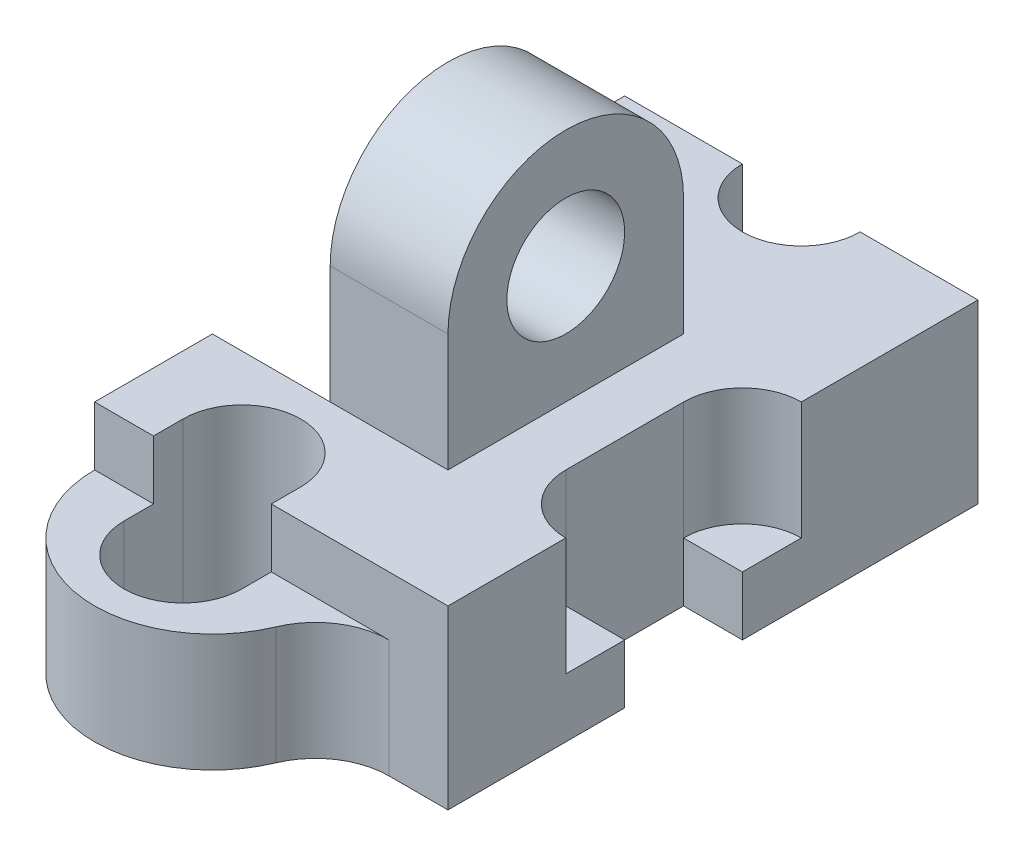
from build123d import *

# Parameters (mm, degrees)
SKETCH1_W           = 6
SKETCH1_H           = 3
BOSS_EXTRUDE1_DEPTH = 9
BOSS_EXTRUDE2_DEPTH = 2
CUT_EXTRUDE1_DEPTH  = 2.5
SKETCH4_W           = 1
SKETCH4_H           = 2
CUT_EXTRUDE2_DEPTH  = 1
CUT_EXTRUDE3_DEPTH  = 2
CUT_EXTRUDE4_DEPTH  = 1
CUT_EXTRUDE5_DEPTH  = 4
SKETCH8_W           = 2
SKETCH8_H           = 4
BOSS_EXTRUDE3_DEPTH = 2
BOSS_EXTRUDE4_DEPTH = 2
SKETCH10_R          = 1
CUT_EXTRUDE6_DEPTH  = 5
SKETCH11_W          = 2
SKETCH11_H          = 4
CUT_EXTRUDE7_DEPTH  = 2
BOSS_EXTRUDE5_DEPTH = 4


with BuildPart() as part:
    # Sketch1 → Boss-Extrude1 (new body)
    with BuildSketch(Plane.XY):
        Rectangle(SKETCH1_W, SKETCH1_H)
    extrude(amount=BOSS_EXTRUDE1_DEPTH)

    # Sketch2 → Boss-Extrude2 (add)
    with BuildSketch(Plane.XZ.offset(1.5)):
        with BuildLine():
            Line((2, 9), (-3, 9))
            ThreePointArc((-3, 9), (-1.39223227, 10.961161351), (0.846153846, 9.769230769))
            ThreePointArc((0.846153846, 9.769230769), (1.306624755, 9.209937132), (2, 9))
        make_face()
    extrude(amount=-BOSS_EXTRUDE2_DEPTH)

    # Sketch3 → Cut-Extrude1 (cut, symmetric)
    with BuildSketch(Plane(origin=(0, 0.5, 0), x_dir=(1, 0, 0), z_dir=(0, 1, 0))):
        with BuildLine():
            Line((-2, -9.5), (-2, -8.5))
            ThreePointArc((-2, -8.5), (-1, -7.5), (0, -8.5))
            Line((0, -8.5), (0, -9.5))
            ThreePointArc((0, -9.5), (-1, -10.5), (-2, -9.5))
        make_face()
    extrude(amount=CUT_EXTRUDE1_DEPTH, both=True, mode=Mode.SUBTRACT)

    # Sketch4 → Cut-Extrude2 (cut)
    with BuildSketch(Plane.XZ.offset(1.5)):
        with Locations((2.5, 5)):
            Rectangle(SKETCH4_W, SKETCH4_H)
    extrude(amount=-CUT_EXTRUDE2_DEPTH, mode=Mode.SUBTRACT)

    # Sketch5 → Cut-Extrude3 (cut)
    with BuildSketch(Plane(origin=(0, 1.5, 0), x_dir=(1, 0, 0), z_dir=(0, 1, 0))):
        with BuildLine():
            Line((4, -4), (4, -6))
            ThreePointArc((4, -6), (3, -7), (2, -6))
            Line((2, -6), (2, -4))
            ThreePointArc((2, -4), (3, -3), (4, -4))
        make_face()
    extrude(amount=-CUT_EXTRUDE3_DEPTH, mode=Mode.SUBTRACT)

    # Sketch6 → Cut-Extrude4 (cut)
    with BuildSketch(Plane.XZ.offset(1.5)):
        with BuildLine():
            Line((2, 0), (-2, 0))
            ThreePointArc((-2, 0), (0, 2), (2, 0))
        make_face()
    extrude(amount=-CUT_EXTRUDE4_DEPTH, mode=Mode.SUBTRACT)

    # Sketch7 → Cut-Extrude5 (cut, through all)
    with BuildSketch(Plane(origin=(0, 1.5, 0), x_dir=(1, 0, 0), z_dir=(0, 1, 0))):
        with BuildLine():
            Line((-1, 0), (1, 0))
            ThreePointArc((1, 0), (0, -1), (-1, 0))
        make_face()
    extrude(amount=-CUT_EXTRUDE5_DEPTH, mode=Mode.SUBTRACT)

    # Sketch8 → Boss-Extrude3 (add)
    with BuildSketch(Plane(origin=(0, 1.5, 0), x_dir=(1, 0, 0), z_dir=(0, 1, 0))):
        with Locations((0, -5)):
            Rectangle(SKETCH8_W, SKETCH8_H)
    extrude(amount=BOSS_EXTRUDE3_DEPTH)

    # Sketch9 → Boss-Extrude4 (add)
    with BuildSketch(Plane(origin=(1, 0, 0), x_dir=(0, 0, -1), z_dir=(1, 0, 0))):
        with BuildLine():
            Line((-3, 3.5), (-7, 3.5))
            ThreePointArc((-7, 3.5), (-5, 5.5), (-3, 3.5))
        make_face()
    extrude(amount=-BOSS_EXTRUDE4_DEPTH)

    # Sketch10 → Cut-Extrude6 (cut, through all)
    with BuildSketch(Plane(origin=(1, 0, 0), x_dir=(0, 0, -1), z_dir=(1, 0, 0))):
        with Locations((-5, 3.5)):
            Circle(SKETCH10_R)
    extrude(amount=-CUT_EXTRUDE6_DEPTH, mode=Mode.SUBTRACT)

    # Sketch11 → Cut-Extrude7 (cut)
    with BuildSketch(Plane(origin=(0, 1.5, 0), x_dir=(1, 0, 0), z_dir=(0, 1, 0))):
        with Locations((-2, -5)):
            Rectangle(SKETCH11_W, SKETCH11_H)
    extrude(amount=-CUT_EXTRUDE7_DEPTH, mode=Mode.SUBTRACT)

    # Sketch12 → Boss-Extrude5 (add)
    with BuildSketch(Plane.XY.offset(3)):
        with BuildLine():
            ThreePointArc((-1, 1.5), (-1.585786438, 0.085786438), (-3, -0.5))
            Line((-3, -0.5), (-1, -0.5))
            Line((-1, -0.5), (-1, 1.5))
        make_face()
    extrude(amount=BOSS_EXTRUDE5_DEPTH)


solid = part.part
